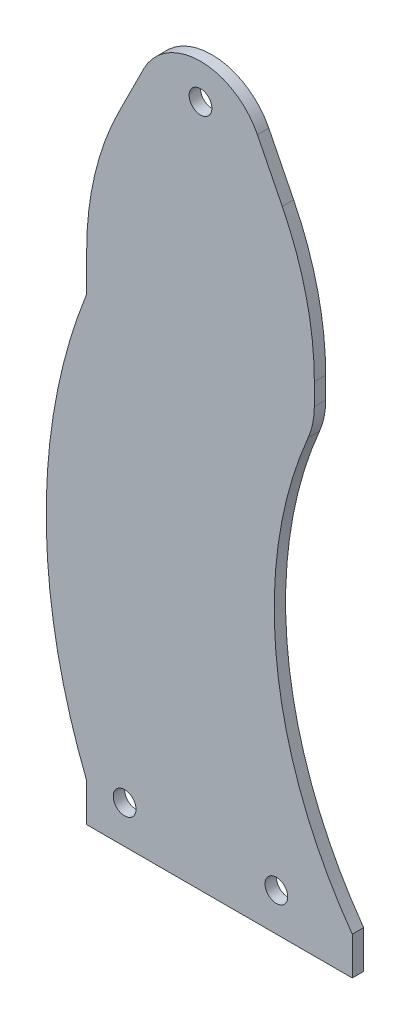
from build123d import *

# Parameters (mm, degrees)
SKETCH_1_R      = 3
EXTRUDE_1_DEPTH = 3


with BuildPart() as part:
    # 草图1 → 凸台-拉伸1 (new body)
    with BuildSketch(Plane.XY):
        with BuildLine():
            Line((8.44582472, 166.89164944), (15, 180))
            ThreePointArc((15, 180), (30, 189.270509831), (45, 180))
            Line((45, 180), (51.55417528, 166.89164944))
            ThreePointArc((51.55417528, 166.89164944), (57.859919157, 149.494795444), (60, 131.1145618))
            Line((60, 131.1145618), (60, 125.412430481))
            ThreePointArc((60, 125.412430481), (59.589066182, 121.379009336), (58.373151387, 117.511335106))
            ThreePointArc((58.373151387, 117.511335106), (50.063143822, 62.228284379), (70, 10))
            Line((70, 10), (70, 0))
            Line((70, 0), (60, 0))
            Line((60, 0), (0, 0))
            Line((0, 0), (0, 10))
            ThreePointArc((0, 10), (-10.668063464, 65.5572809), (0, 121.1145618))
            Line((0, 121.1145618), (0, 131.1145618))
            ThreePointArc((0, 131.1145618), (2.140080843, 149.494795444), (8.44582472, 166.89164944))
        make_face()
        with Locations((10, 10)):
            Circle(SKETCH_1_R, mode=Mode.SUBTRACT)
        with Locations((50, 10)):
            Circle(SKETCH_1_R, mode=Mode.SUBTRACT)
        with Locations((30, 180)):
            Circle(SKETCH_1_R, mode=Mode.SUBTRACT)
    extrude(amount=EXTRUDE_1_DEPTH)


solid = part.part
